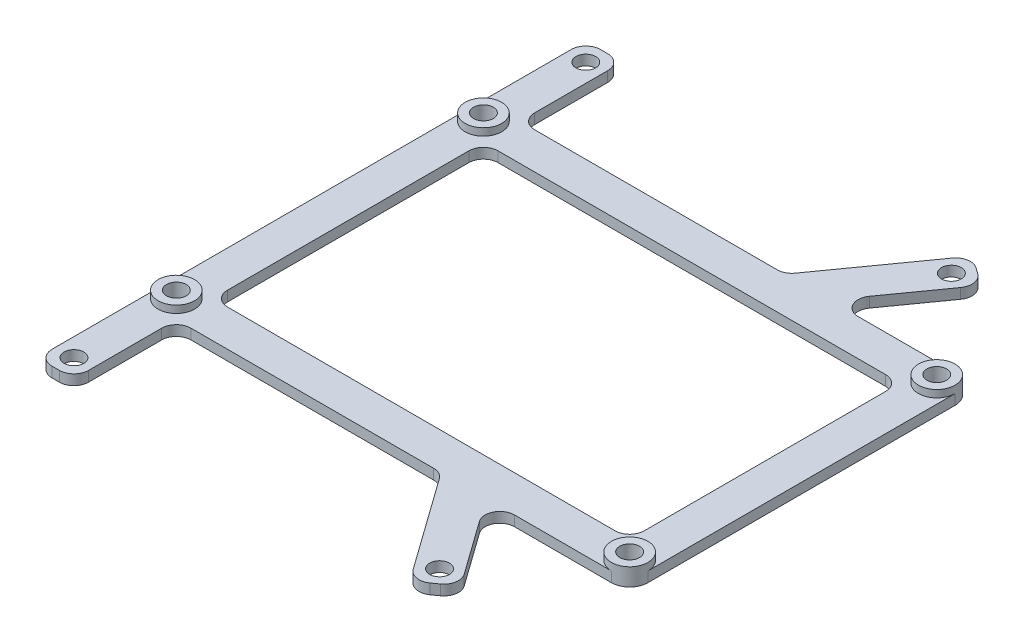
from build123d import *

# Parameters (mm, degrees)
SKETCH2_W           = 57
SKETCH2_H           = 37
BOSS_EXTRUDE1_DEPTH = 1.4
SKETCH1_R           = 1.35
CUT_EXTRUDE2_DEPTH  = 2.4
FILLET1_R           = 2
FILLET2_R           = 2
SKETCH4_R           = 2.5
SKETCH4_R_2         = 1.35
BOSS_EXTRUDE2_DEPTH = 1
CUT_EXTRUDE3_DEPTH  = 2.4


with BuildPart() as part:
    # Sketch2 → Boss-Extrude1 (new body)
    with BuildSketch(Plane(origin=(0, 0, 0), x_dir=(1, 0, 0), z_dir=(0, 1, 0))):
        Polygon((-27.5, -37.5), (-27.5, 37.5), (-22.5, 37.5), (-22.5, 23.5), (13.713455262, 23.5), (24.418761806, 38.487429162), (28.487429162, 35.581238194), (19.85797331, 23.5), (39.5, 23.5), (39.5, -23.5), (19.85797331, -23.5), (28.487429162, -35.581238194), (24.418761806, -38.487429162), (13.713455262, -23.5), (-22.5, -23.5), (-22.5, -37.5), align=None)
        with Locations((6, 0)):
            Rectangle(SKETCH2_W, SKETCH2_H, mode=Mode.SUBTRACT)
    extrude(amount=BOSS_EXTRUDE1_DEPTH)

    # Sketch1 → Cut-Extrude2 (cut, through all)
    with BuildSketch(Plane(origin=(0, 0, 0), x_dir=(1, 0, 0), z_dir=(0, 1, 0))):
        with Locations((-25, 35)):
            Circle(SKETCH1_R)
        with Locations((25, 35)):
            Circle(SKETCH1_R)
        with Locations((25, -35)):
            Circle(SKETCH1_R)
        with Locations((-25, -35)):
            Circle(SKETCH1_R)
        with Locations((-25, 21)):
            Circle(SKETCH1_R)
        with Locations((37, 21)):
            Circle(SKETCH1_R)
        with Locations((37, -21)):
            Circle(SKETCH1_R)
        with Locations((-25, -21)):
            Circle(SKETCH1_R)
    extrude(amount=CUT_EXTRUDE2_DEPTH, mode=Mode.SUBTRACT)

    # Fillet1
    fillet1_edges = [part.edges().sort_by_distance(p)[0] for p in [
        (28.487429162, 0.7, 35.581238194),
        (24.418761806, 0.7, 38.487429162),
        (-22.5, 0.7, 37.5),
        (-27.5, 0.7, 37.5),
        (-27.5, 0.7, -37.5),
        (-22.5, 0.7, -37.5),
        (24.418761806, 0.7, -38.487429162),
        (28.487429162, 0.7, -35.581238194),
    ]]
    fillet(fillet1_edges, radius=FILLET1_R)

    # Fillet2
    fillet2_edges = [part.edges().sort_by_distance(p)[0] for p in [
        (13.713455262, 0.7, 23.5),
        (-22.5, 0.7, 23.5),
        (-22.5, 0.7, -23.5),
        (13.713455262, 0.7, -23.5),
        (19.85797331, 0.7, -23.5),
        (19.85797331, 0.7, 23.5),
        (-22.5, 0.7, 18.5),
        (34.5, 0.7, 18.5),
        (34.5, 0.7, -18.5),
        (-22.5, 0.7, -18.5),
    ]]
    fillet(fillet2_edges, radius=FILLET2_R)

    # Sketch4 → Boss-Extrude2 (add)
    with BuildSketch(Plane(origin=(0, 1.4, 0), x_dir=(1, 0, 0), z_dir=(0, 1, 0))):
        with Locations((37, 21)):
            Circle(SKETCH4_R)
        with Locations((37, 21)):
            Circle(SKETCH4_R_2, mode=Mode.SUBTRACT)
        with Locations((37, -21)):
            Circle(SKETCH4_R)
        with Locations((37, -21)):
            Circle(SKETCH4_R_2, mode=Mode.SUBTRACT)
        with Locations((-25, -21)):
            Circle(SKETCH4_R)
        with Locations((-25, -21)):
            Circle(SKETCH4_R_2, mode=Mode.SUBTRACT)
        with Locations((-25, 21)):
            Circle(SKETCH4_R)
        with Locations((-25, 21)):
            Circle(SKETCH4_R_2, mode=Mode.SUBTRACT)
    extrude(amount=BOSS_EXTRUDE2_DEPTH)

    # Sketch5 → Cut-Extrude3 (cut, through all)
    with BuildSketch(Plane(origin=(0, 1.4, 0), x_dir=(1, 0, 0), z_dir=(0, 1, 0))):
        with BuildLine():
            Line((37, -23.5), (39.5, -23.5))
            Line((39.5, -23.5), (39.5, -21))
            ThreePointArc((39.5, -21), (38.767766953, -22.767766953), (37, -23.5))
        make_face()
        with BuildLine():
            Line((39.5, 21), (39.5, 23.5))
            Line((39.5, 23.5), (37, 23.5))
            ThreePointArc((37, 23.5), (38.767766953, 22.767766953), (39.5, 21))
        make_face()
    extrude(amount=-CUT_EXTRUDE3_DEPTH, mode=Mode.SUBTRACT)


solid = part.part
